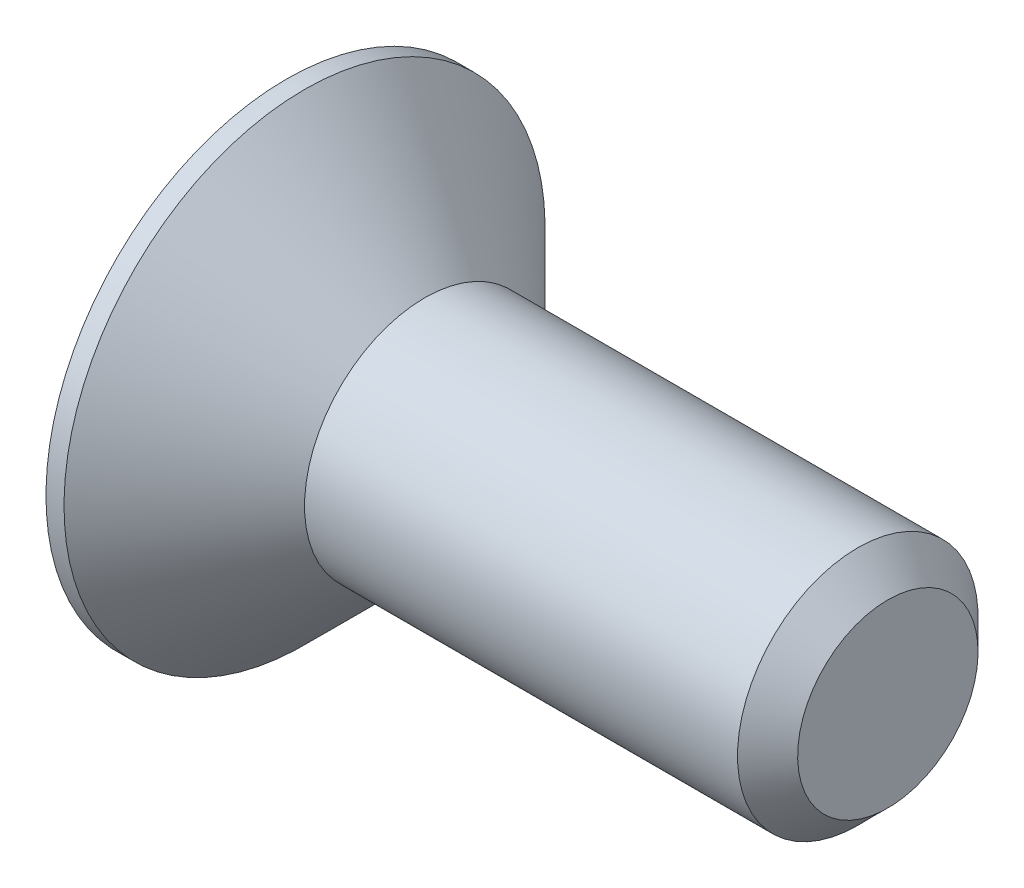
from build123d import *

# Parameters (mm, degrees)
CHANFREIN1_SIZE         = 0.5
ENL_V_MAT_EXTRU_1_DEPTH = 1.8


with BuildPart() as part:
    # Esquisse1 → Révolution1 (revolve)
    with BuildSketch(Plane.XY):
        Polygon((0, 0), (0, 4), (0.3, 4), (2.3, 2), (10, 2), (10, 0), align=None)
    revolve(axis=Axis((10, 0, 0), (-1, 0, 0)))

    # Chanfrein1
    chanfrein1_edges = [part.edges().sort_by_distance(p)[0] for p in [
        (10, -2, 0),
    ]]
    chamfer(chanfrein1_edges, length=CHANFREIN1_SIZE)

    # Esquisse2 → Enlèv. mat.-Extru.1 (cut)
    with BuildSketch(Plane.ZY):
        Polygon((0, 1.443375673), (-1.25, 0.721687836), (-1.25, -0.721687836), (0, -1.443375673), (1.25, -0.721687836), (1.25, 0.721687836), align=None)
    extrude(amount=-ENL_V_MAT_EXTRU_1_DEPTH, mode=Mode.SUBTRACT)


solid = part.part
